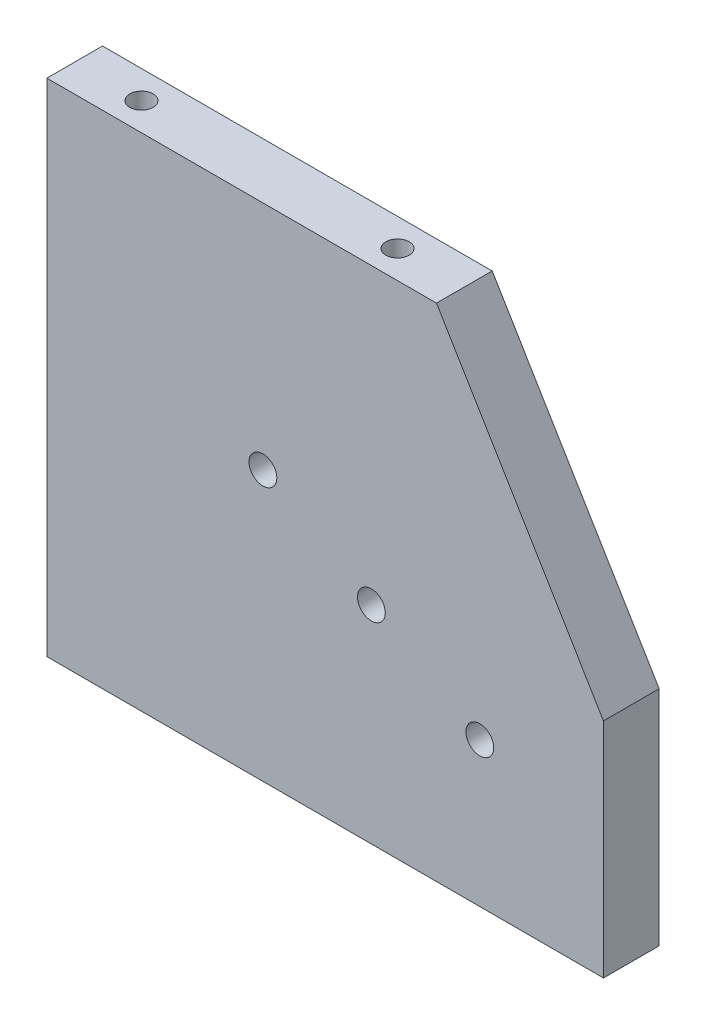
from build123d import *

# Parameters (mm, degrees)
BOSS_EXTRUDE1_DEPTH   = 10
M6_TAPPED_HOLE1_D     = 5
M6_TAPPED_HOLE1_DEPTH = 15
M6_TAPPED_HOLE1_TIP   = 1.502151548
M5_TAPPED_HOLE1_D     = 4.2
M5_TAPPED_HOLE1_DEPTH = 8
M5_TAPPED_HOLE1_TIP   = 1.2618073


with BuildPart() as part:
    # Sketch2 → Boss-Extrude1 (new body)
    with BuildSketch(Plane.XY):
        Polygon((39.684210526, 32.684210526), (69.684210526, -17.315789474), (69.684210526, -57.315789474), (-30.315789474, -57.315789474), (-30.315789474, 32.684210526), align=None)
    extrude(amount=BOSS_EXTRUDE1_DEPTH)

    # M6 Tapped Hole1
    with Locations(Plane.XY.offset(10)):
        with Locations((8.498638941, -8.865789474), (47.469782111, -31.365789474), (27.984210526, -20.115789474)):
            Hole(M6_TAPPED_HOLE1_D / 2, depth=M6_TAPPED_HOLE1_DEPTH)
            with Locations((0, 0, -(M6_TAPPED_HOLE1_DEPTH + M6_TAPPED_HOLE1_TIP / 2))):  # 118° drill point
                Cone(0, M6_TAPPED_HOLE1_D / 2, M6_TAPPED_HOLE1_TIP, mode=Mode.SUBTRACT)

    # M5 Tapped Hole1
    with Locations(Plane(origin=(0, 32.684210526, 0), x_dir=(1, 0, 0), z_dir=(0, 1, 0))):
        with Locations((-18.315789474, -5), (27.684210526, -5)):
            Hole(M5_TAPPED_HOLE1_D / 2, depth=M5_TAPPED_HOLE1_DEPTH)
            with Locations((0, 0, -(M5_TAPPED_HOLE1_DEPTH + M5_TAPPED_HOLE1_TIP / 2))):  # 118° drill point
                Cone(0, M5_TAPPED_HOLE1_D / 2, M5_TAPPED_HOLE1_TIP, mode=Mode.SUBTRACT)


solid = part.part
